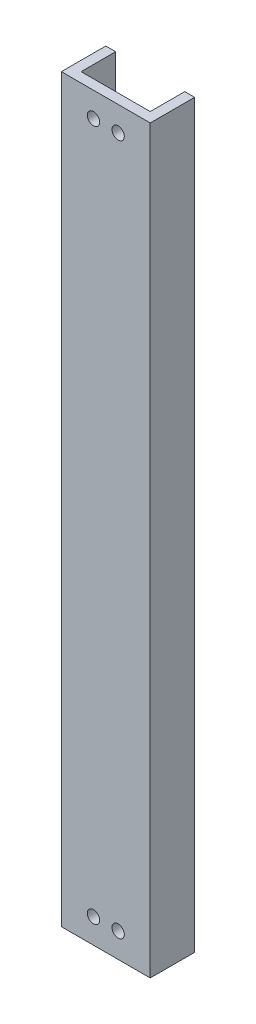
from build123d import *

# Parameters (mm, degrees)
BOSS_EXTRUDE1_DEPTH = 150
SKETCH2_R           = 1.25
CUT_EXTRUDE1_DEPTH  = 10


with BuildPart() as part:
    # Sketch1 → Boss-Extrude1 (new body)
    with BuildSketch(Plane(origin=(0, 0, 0), x_dir=(1, 0, 0), z_dir=(0, 1, 0))):
        Polygon((-7, 4.5), (-7, -2.5), (7, -2.5), (7, 4.5), (9, 4.5), (9, -4.5), (-9, -4.5), (-9, 4.5), align=None)
    extrude(amount=BOSS_EXTRUDE1_DEPTH)

    # Sketch2 → Cut-Extrude1 (cut)
    with BuildSketch(Plane(origin=(0, 0, 2.5), x_dir=(-1, 0, 0), z_dir=(0, 0, -1))):
        with Locations((-2.5, 5)):
            Circle(SKETCH2_R)
        with Locations((2.5, 5)):
            Circle(SKETCH2_R)
        with Locations((2.5, 145)):
            Circle(SKETCH2_R)
        with Locations((-2.5, 145)):
            Circle(SKETCH2_R)
    extrude(amount=-CUT_EXTRUDE1_DEPTH, mode=Mode.SUBTRACT)


solid = part.part
